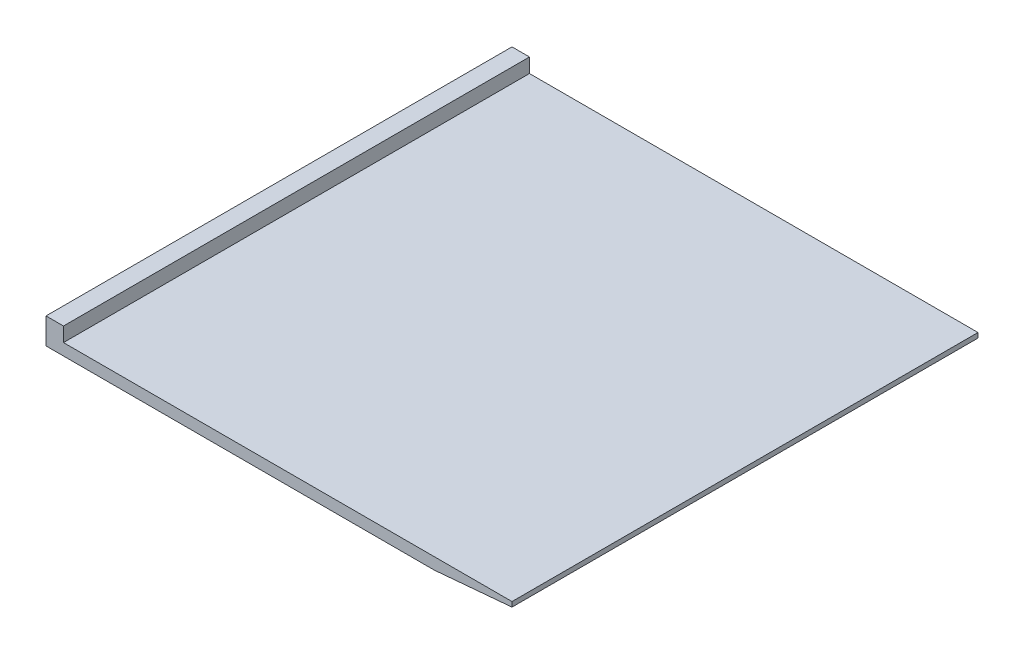
from build123d import *

# Parameters (mm, degrees)
SKETCH1_W           = 60
SKETCH1_H           = 60
BOSS_EXTRUDE1_DEPTH = 1.5
SKETCH4_W           = 2.25
SKETCH4_H           = 60
BOSS_EXTRUDE2_DEPTH = 1.85
CHAMFER1_SIZE       = 10
CHAMFER1_SIZE2      = 0.874886635


with BuildPart() as part:
    # Sketch1 → Boss-Extrude1 (new body)
    with BuildSketch(Plane(origin=(0, 0, 0), x_dir=(1, 0, 0), z_dir=(0, 1, 0))):
        Rectangle(SKETCH1_W, SKETCH1_H)
    extrude(amount=BOSS_EXTRUDE1_DEPTH)

    # Sketch4 → Boss-Extrude2 (add)
    with BuildSketch(Plane(origin=(0, 1.5, 0), x_dir=(1, 0, 0), z_dir=(0, 1, 0))):
        with Locations((-28.875, 0)):
            Rectangle(SKETCH4_W, SKETCH4_H)
    extrude(amount=BOSS_EXTRUDE2_DEPTH)

    # Chamfer1
    chamfer1_edges = [part.edges().sort_by_distance(p)[0] for p in [
        (30, 0, 0),
    ]]
    chamfer1_side = [part.faces().sort_by_distance(p)[0] for p in [
        (0, 0, 0),
    ]]
    chamfer(chamfer1_edges, length=CHAMFER1_SIZE, length2=CHAMFER1_SIZE2, reference=chamfer1_side[0])


solid = part.part
